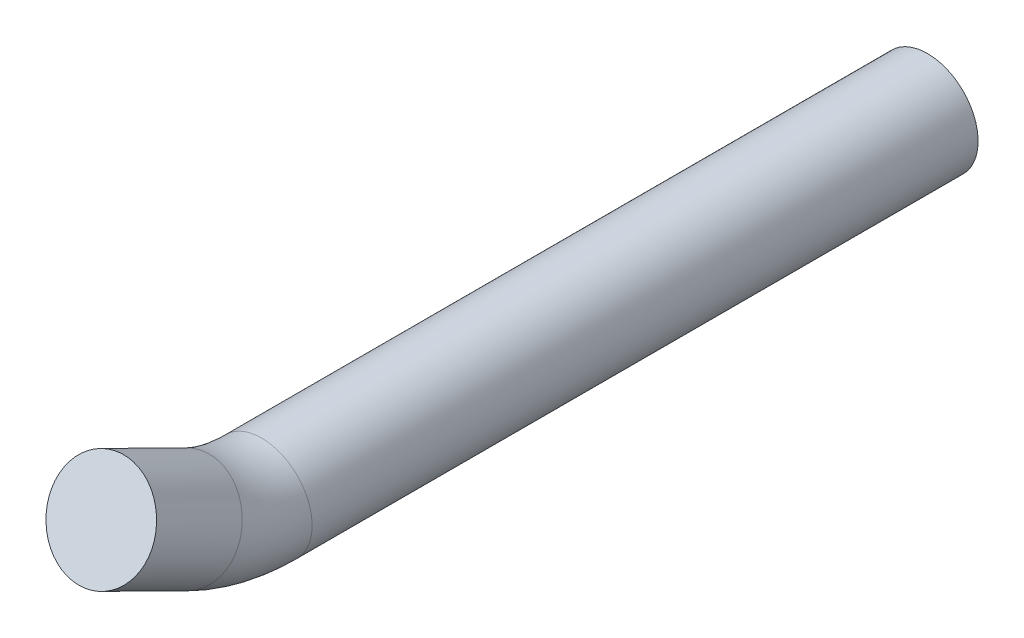
from build123d import *

# Parameters (mm, degrees)
CROQUIS1_R              = 15
SALIENTE_EXTRUIR1_DEPTH = 170
CROQUIS2_R              = 15
CROQUIS3_R              = 15
SALIENTE_EXTRUIR2_DEPTH = 20


with BuildPart() as part:
    # Croquis1 → Saliente-Extruir1 (new body)
    with BuildSketch(Plane.XY):
        Circle(CROQUIS1_R)
    extrude(amount=SALIENTE_EXTRUIR1_DEPTH)

    # Barrer1: sweep along a curve in space
    with BuildLine() as barrer1_path:
        Line((0, 0, 170), (0, 0, 177.4880174))
        ThreePointArc((0, 0, 177.4880174), (0, 1.310507191, 188.860496902), (0, 5.173331601, 199.636827757))
        Line((0, 5.173331601, 199.636827757), (0, 17.719048286, 225.027928795))
    # Croquis2 → Barrer1 (sweep)
    with BuildSketch(Plane.XY.offset(170)):
        Circle(CROQUIS2_R)
    sweep(path=barrer1_path.line)

    # Croquis3 → Saliente-Extruir2 (add)
    with BuildSketch(Plane(origin=(0, 0, 0), x_dir=(-1, 0, 0), z_dir=(0, 0, -1))):
        Circle(CROQUIS3_R)
    extrude(amount=SALIENTE_EXTRUIR2_DEPTH)


solid = part.part
